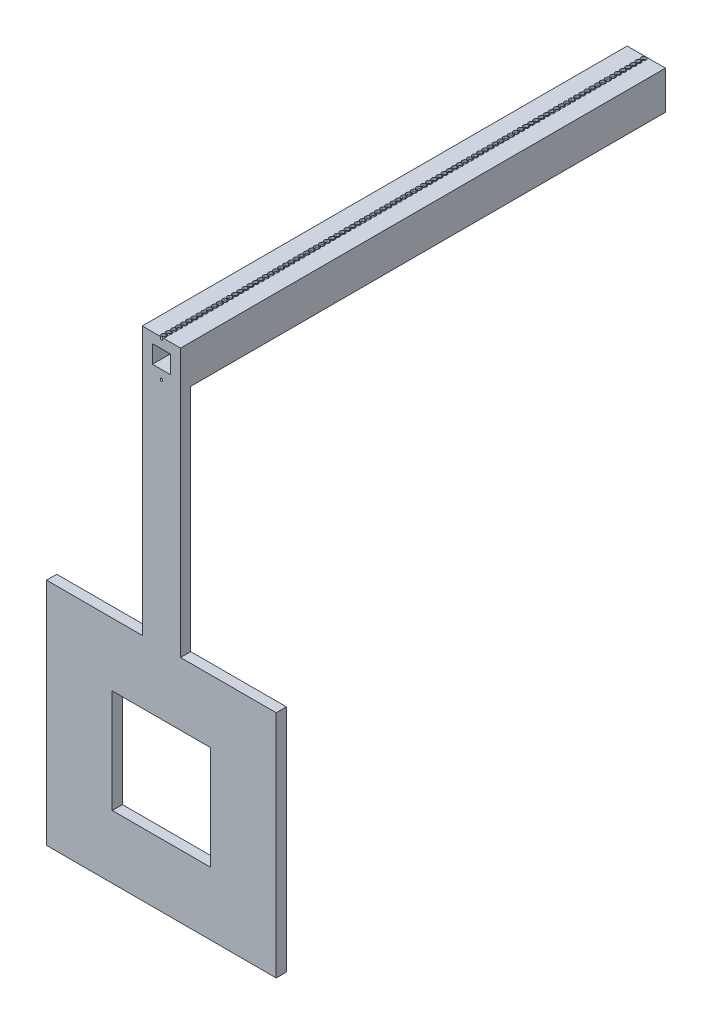
from build123d import *

# Parameters (mm, degrees)
SKETCH1_W                = 7.5
SKETCH1_H                = 7.5
SKETCH1_W_2              = 3.5
SKETCH1_H_2              = 3.5
BOSS_EXTRUDE1_DEPTH      = 95
SKETCH2_W                = 19.264715996
SKETCH2_H                = 20.292256916
BOSS_EXTRUDE2_DEPTH      = 2
SKETCH5_R                = 0.505131084
CUT_EXTRUDE2_DEPTH       = 0.5
LPATTERN1_COUNT          = 100
LPATTERN1_PITCH          = 1
MIRROR1_COPY_1_SKETCH_R  = 0.505131084
MIRROR1_COPY_1_DEPTH     = 0.5
MIRROR1_COPY_2_SKETCH_R  = 0.505131084
MIRROR1_COPY_2_DEPTH     = 0.5
MIRROR1_COPY_3_SKETCH_R  = 0.505131084
MIRROR1_COPY_3_DEPTH     = 0.5
MIRROR1_COPY_4_SKETCH_R  = 0.505131084
MIRROR1_COPY_4_DEPTH     = 0.5
MIRROR1_COPY_5_SKETCH_R  = 0.505131084
MIRROR1_COPY_5_DEPTH     = 0.5
MIRROR1_COPY_6_SKETCH_R  = 0.505131084
MIRROR1_COPY_6_DEPTH     = 0.5
MIRROR1_COPY_7_SKETCH_R  = 0.505131084
MIRROR1_COPY_7_DEPTH     = 0.5
MIRROR1_COPY_8_SKETCH_R  = 0.505131084
MIRROR1_COPY_8_DEPTH     = 0.5
MIRROR1_COPY_9_SKETCH_R  = 0.505131084
MIRROR1_COPY_9_DEPTH     = 0.5
MIRROR1_COPY_10_SKETCH_R = 0.505131084
MIRROR1_COPY_10_DEPTH    = 0.5
MIRROR1_COPY_11_SKETCH_R = 0.505131084
MIRROR1_COPY_11_DEPTH    = 0.5
MIRROR1_COPY_12_SKETCH_R = 0.505131084
MIRROR1_COPY_12_DEPTH    = 0.5
MIRROR1_COPY_13_SKETCH_R = 0.505131084
MIRROR1_COPY_13_DEPTH    = 0.5
MIRROR1_COPY_14_SKETCH_R = 0.505131084
MIRROR1_COPY_14_DEPTH    = 0.5
MIRROR1_COPY_15_SKETCH_R = 0.505131084
MIRROR1_COPY_15_DEPTH    = 0.5
MIRROR1_COPY_16_SKETCH_R = 0.505131084
MIRROR1_COPY_16_DEPTH    = 0.5
MIRROR1_COPY_17_SKETCH_R = 0.505131084
MIRROR1_COPY_17_DEPTH    = 0.5
MIRROR1_COPY_18_SKETCH_R = 0.505131084
MIRROR1_COPY_18_DEPTH    = 0.5
MIRROR1_COPY_19_SKETCH_R = 0.505131084
MIRROR1_COPY_19_DEPTH    = 0.5
MIRROR1_COPY_20_SKETCH_R = 0.505131084
MIRROR1_COPY_20_DEPTH    = 0.5
MIRROR1_COPY_21_SKETCH_R = 0.505131084
MIRROR1_COPY_21_DEPTH    = 0.5
MIRROR1_COPY_22_SKETCH_R = 0.505131084
MIRROR1_COPY_22_DEPTH    = 0.5
MIRROR1_COPY_23_SKETCH_R = 0.505131084
MIRROR1_COPY_23_DEPTH    = 0.5
MIRROR1_COPY_24_SKETCH_R = 0.505131084
MIRROR1_COPY_24_DEPTH    = 0.5
MIRROR1_COPY_25_SKETCH_R = 0.505131084
MIRROR1_COPY_25_DEPTH    = 0.5
MIRROR1_COPY_26_SKETCH_R = 0.505131084
MIRROR1_COPY_26_DEPTH    = 0.5
MIRROR1_COPY_27_SKETCH_R = 0.505131084
MIRROR1_COPY_27_DEPTH    = 0.5
MIRROR1_COPY_28_SKETCH_R = 0.505131084
MIRROR1_COPY_28_DEPTH    = 0.5
MIRROR1_COPY_29_SKETCH_R = 0.505131084
MIRROR1_COPY_29_DEPTH    = 0.5
MIRROR1_COPY_30_SKETCH_R = 0.505131084
MIRROR1_COPY_30_DEPTH    = 0.5
MIRROR1_COPY_31_SKETCH_R = 0.505131084
MIRROR1_COPY_31_DEPTH    = 0.5
MIRROR1_COPY_32_SKETCH_R = 0.505131084
MIRROR1_COPY_32_DEPTH    = 0.5
MIRROR1_COPY_33_SKETCH_R = 0.505131084
MIRROR1_COPY_33_DEPTH    = 0.5
MIRROR1_COPY_34_SKETCH_R = 0.505131084
MIRROR1_COPY_34_DEPTH    = 0.5
MIRROR1_COPY_35_SKETCH_R = 0.505131084
MIRROR1_COPY_35_DEPTH    = 0.5
MIRROR1_COPY_36_SKETCH_R = 0.505131084
MIRROR1_COPY_36_DEPTH    = 0.5
MIRROR1_COPY_37_SKETCH_R = 0.505131084
MIRROR1_COPY_37_DEPTH    = 0.5
MIRROR1_COPY_38_SKETCH_R = 0.505131084
MIRROR1_COPY_38_DEPTH    = 0.5
MIRROR1_COPY_39_SKETCH_R = 0.505131084
MIRROR1_COPY_39_DEPTH    = 0.5
MIRROR1_COPY_40_SKETCH_R = 0.505131084
MIRROR1_COPY_40_DEPTH    = 0.5
MIRROR1_COPY_41_SKETCH_R = 0.505131084
MIRROR1_COPY_41_DEPTH    = 0.5
MIRROR1_COPY_42_SKETCH_R = 0.505131084
MIRROR1_COPY_42_DEPTH    = 0.5
MIRROR1_COPY_43_SKETCH_R = 0.505131084
MIRROR1_COPY_43_DEPTH    = 0.5
MIRROR1_COPY_44_SKETCH_R = 0.505131084
MIRROR1_COPY_44_DEPTH    = 0.5
MIRROR1_COPY_45_SKETCH_R = 0.505131084
MIRROR1_COPY_45_DEPTH    = 0.5
MIRROR1_COPY_46_SKETCH_R = 0.505131084
MIRROR1_COPY_46_DEPTH    = 0.5
MIRROR1_COPY_47_SKETCH_R = 0.505131084
MIRROR1_COPY_47_DEPTH    = 0.5
MIRROR1_COPY_48_SKETCH_R = 0.505131084
MIRROR1_COPY_48_DEPTH    = 0.5
MIRROR1_COPY_49_SKETCH_R = 0.505131084
MIRROR1_COPY_49_DEPTH    = 0.5
MIRROR1_COPY_50_SKETCH_R = 0.505131084
MIRROR1_COPY_50_DEPTH    = 0.5
MIRROR1_COPY_51_SKETCH_R = 0.505131084
MIRROR1_COPY_51_DEPTH    = 0.5
MIRROR1_COPY_52_SKETCH_R = 0.505131084
MIRROR1_COPY_52_DEPTH    = 0.5
MIRROR1_COPY_53_SKETCH_R = 0.505131084
MIRROR1_COPY_53_DEPTH    = 0.5
MIRROR1_COPY_54_SKETCH_R = 0.505131084
MIRROR1_COPY_54_DEPTH    = 0.5
MIRROR1_COPY_55_SKETCH_R = 0.505131084
MIRROR1_COPY_55_DEPTH    = 0.5
MIRROR1_COPY_56_SKETCH_R = 0.505131084
MIRROR1_COPY_56_DEPTH    = 0.5
MIRROR1_COPY_57_SKETCH_R = 0.505131084
MIRROR1_COPY_57_DEPTH    = 0.5
MIRROR1_COPY_58_SKETCH_R = 0.505131084
MIRROR1_COPY_58_DEPTH    = 0.5
MIRROR1_COPY_59_SKETCH_R = 0.505131084
MIRROR1_COPY_59_DEPTH    = 0.5
MIRROR1_COPY_60_SKETCH_R = 0.505131084
MIRROR1_COPY_60_DEPTH    = 0.5
MIRROR1_COPY_61_SKETCH_R = 0.505131084
MIRROR1_COPY_61_DEPTH    = 0.5
MIRROR1_COPY_62_SKETCH_R = 0.505131084
MIRROR1_COPY_62_DEPTH    = 0.5
MIRROR1_COPY_63_SKETCH_R = 0.505131084
MIRROR1_COPY_63_DEPTH    = 0.5
MIRROR1_COPY_64_SKETCH_R = 0.505131084
MIRROR1_COPY_64_DEPTH    = 0.5
MIRROR1_COPY_65_SKETCH_R = 0.505131084
MIRROR1_COPY_65_DEPTH    = 0.5
MIRROR1_COPY_66_SKETCH_R = 0.505131084
MIRROR1_COPY_66_DEPTH    = 0.5
MIRROR1_COPY_67_SKETCH_R = 0.505131084
MIRROR1_COPY_67_DEPTH    = 0.5
MIRROR1_COPY_68_SKETCH_R = 0.505131084
MIRROR1_COPY_68_DEPTH    = 0.5
MIRROR1_COPY_69_SKETCH_R = 0.505131084
MIRROR1_COPY_69_DEPTH    = 0.5
MIRROR1_COPY_70_SKETCH_R = 0.505131084
MIRROR1_COPY_70_DEPTH    = 0.5
MIRROR1_COPY_71_SKETCH_R = 0.505131084
MIRROR1_COPY_71_DEPTH    = 0.5
MIRROR1_COPY_72_SKETCH_R = 0.505131084
MIRROR1_COPY_72_DEPTH    = 0.5
MIRROR1_COPY_73_SKETCH_R = 0.505131084
MIRROR1_COPY_73_DEPTH    = 0.5
MIRROR1_COPY_74_SKETCH_R = 0.505131084
MIRROR1_COPY_74_DEPTH    = 0.5
MIRROR1_COPY_75_SKETCH_R = 0.505131084
MIRROR1_COPY_75_DEPTH    = 0.5
MIRROR1_COPY_76_SKETCH_R = 0.505131084
MIRROR1_COPY_76_DEPTH    = 0.5
MIRROR1_COPY_77_SKETCH_R = 0.505131084
MIRROR1_COPY_77_DEPTH    = 0.5
MIRROR1_COPY_78_SKETCH_R = 0.505131084
MIRROR1_COPY_78_DEPTH    = 0.5
MIRROR1_COPY_79_SKETCH_R = 0.505131084
MIRROR1_COPY_79_DEPTH    = 0.5
MIRROR1_COPY_80_SKETCH_R = 0.505131084
MIRROR1_COPY_80_DEPTH    = 0.5
MIRROR1_COPY_81_SKETCH_R = 0.505131084
MIRROR1_COPY_81_DEPTH    = 0.5
MIRROR1_COPY_82_SKETCH_R = 0.505131084
MIRROR1_COPY_82_DEPTH    = 0.5
MIRROR1_COPY_83_SKETCH_R = 0.505131084
MIRROR1_COPY_83_DEPTH    = 0.5
MIRROR1_COPY_84_SKETCH_R = 0.505131084
MIRROR1_COPY_84_DEPTH    = 0.5
MIRROR1_COPY_85_SKETCH_R = 0.505131084
MIRROR1_COPY_85_DEPTH    = 0.5
MIRROR1_COPY_86_SKETCH_R = 0.505131084
MIRROR1_COPY_86_DEPTH    = 0.5
MIRROR1_COPY_87_SKETCH_R = 0.505131084
MIRROR1_COPY_87_DEPTH    = 0.5
MIRROR1_COPY_88_SKETCH_R = 0.505131084
MIRROR1_COPY_88_DEPTH    = 0.5
MIRROR1_COPY_89_SKETCH_R = 0.505131084
MIRROR1_COPY_89_DEPTH    = 0.5
MIRROR1_COPY_90_SKETCH_R = 0.505131084
MIRROR1_COPY_90_DEPTH    = 0.5
MIRROR1_COPY_91_SKETCH_R = 0.505131084
MIRROR1_COPY_91_DEPTH    = 0.5
MIRROR1_COPY_92_SKETCH_R = 0.505131084
MIRROR1_COPY_92_DEPTH    = 0.5
MIRROR1_COPY_93_SKETCH_R = 0.505131084
MIRROR1_COPY_93_DEPTH    = 0.5
MIRROR1_COPY_94_SKETCH_R = 0.505131084
MIRROR1_COPY_94_DEPTH    = 0.5
MIRROR1_COPY_95_SKETCH_R = 0.505131084
MIRROR1_COPY_95_DEPTH    = 0.5
MIRROR1_COPY_96_SKETCH_R = 0.505131084
MIRROR1_COPY_96_DEPTH    = 0.5
MIRROR1_COPY_97_SKETCH_R = 0.505131084
MIRROR1_COPY_97_DEPTH    = 0.5
MIRROR1_COPY_98_SKETCH_R = 0.505131084
MIRROR1_COPY_98_DEPTH    = 0.5
MIRROR1_COPY_99_SKETCH_R = 0.505131084
MIRROR1_COPY_99_DEPTH    = 0.5


with BuildPart() as part:
    # Sketch1 → Boss-Extrude1 (new body)
    with BuildSketch(Plane.XY):
        Rectangle(SKETCH1_W, SKETCH1_H)
        Rectangle(SKETCH1_W_2, SKETCH1_H_2, mode=Mode.SUBTRACT)
    extrude(amount=BOSS_EXTRUDE1_DEPTH)

    # Sketch2 → Boss-Extrude2 (add)
    with BuildSketch(Plane.XY.offset(95)):
        Polygon((3.75, -3.75), (-3.75, -3.75), (-3.75, -48.75), (-22.5, -48.75), (-22.5, -93.75), (22.5, -93.75), (22.5, -48.75), (3.75, -48.75), align=None)
        with Locations((0, -71.25)):
            Rectangle(SKETCH2_W, SKETCH2_H, mode=Mode.SUBTRACT)
    extrude(amount=-BOSS_EXTRUDE2_DEPTH)

    # Sketch5 → Cut-Extrude2 (cut)
    with BuildSketch(Plane(origin=(0, 3.75, 0), x_dir=(1, 0, 0), z_dir=(0, 1, 0))):
        with Locations(Location((0, -0.542844407, 0), (0, 0, 270))):
            Circle(SKETCH5_R)
    cut_extrude2 = extrude(amount=-CUT_EXTRUDE2_DEPTH, mode=Mode.SUBTRACT)

    # LPattern1: Cut-Extrude2 ×100
    with Locations(*[(0, 0, i * LPATTERN1_PITCH) for i in range(1, LPATTERN1_COUNT)]):
        add(cut_extrude2, mode=Mode.SUBTRACT)

    # Mirror1: Cut-Extrude2 across plane
    add(cut_extrude2.mirror(Plane.ZX), mode=Mode.SUBTRACT)

    # Mirror1 copy 1 sketch → Mirror1 copy 1 (cut)
    with BuildSketch(Plane(origin=(0, -3.75, 1), x_dir=(1, 0, 0), z_dir=(0, -1, 0))):
        with Locations((0, 0.542844407)):
            Circle(MIRROR1_COPY_1_SKETCH_R)
    extrude(amount=-MIRROR1_COPY_1_DEPTH, mode=Mode.SUBTRACT)

    # Mirror1 copy 2 sketch → Mirror1 copy 2 (cut)
    with BuildSketch(Plane(origin=(0, -3.75, 2), x_dir=(1, 0, 0), z_dir=(0, -1, 0))):
        with Locations((0, 0.542844407)):
            Circle(MIRROR1_COPY_2_SKETCH_R)
    extrude(amount=-MIRROR1_COPY_2_DEPTH, mode=Mode.SUBTRACT)

    # Mirror1 copy 3 sketch → Mirror1 copy 3 (cut)
    with BuildSketch(Plane(origin=(0, -3.75, 3), x_dir=(1, 0, 0), z_dir=(0, -1, 0))):
        with Locations((0, 0.542844407)):
            Circle(MIRROR1_COPY_3_SKETCH_R)
    extrude(amount=-MIRROR1_COPY_3_DEPTH, mode=Mode.SUBTRACT)

    # Mirror1 copy 4 sketch → Mirror1 copy 4 (cut)
    with BuildSketch(Plane(origin=(0, -3.75, 4), x_dir=(1, 0, 0), z_dir=(0, -1, 0))):
        with Locations((0, 0.542844407)):
            Circle(MIRROR1_COPY_4_SKETCH_R)
    extrude(amount=-MIRROR1_COPY_4_DEPTH, mode=Mode.SUBTRACT)

    # Mirror1 copy 5 sketch → Mirror1 copy 5 (cut)
    with BuildSketch(Plane(origin=(0, -3.75, 5), x_dir=(1, 0, 0), z_dir=(0, -1, 0))):
        with Locations((0, 0.542844407)):
            Circle(MIRROR1_COPY_5_SKETCH_R)
    extrude(amount=-MIRROR1_COPY_5_DEPTH, mode=Mode.SUBTRACT)

    # Mirror1 copy 6 sketch → Mirror1 copy 6 (cut)
    with BuildSketch(Plane(origin=(0, -3.75, 6), x_dir=(1, 0, 0), z_dir=(0, -1, 0))):
        with Locations((0, 0.542844407)):
            Circle(MIRROR1_COPY_6_SKETCH_R)
    extrude(amount=-MIRROR1_COPY_6_DEPTH, mode=Mode.SUBTRACT)

    # Mirror1 copy 7 sketch → Mirror1 copy 7 (cut)
    with BuildSketch(Plane(origin=(0, -3.75, 7), x_dir=(1, 0, 0), z_dir=(0, -1, 0))):
        with Locations((0, 0.542844407)):
            Circle(MIRROR1_COPY_7_SKETCH_R)
    extrude(amount=-MIRROR1_COPY_7_DEPTH, mode=Mode.SUBTRACT)

    # Mirror1 copy 8 sketch → Mirror1 copy 8 (cut)
    with BuildSketch(Plane(origin=(0, -3.75, 8), x_dir=(1, 0, 0), z_dir=(0, -1, 0))):
        with Locations((0, 0.542844407)):
            Circle(MIRROR1_COPY_8_SKETCH_R)
    extrude(amount=-MIRROR1_COPY_8_DEPTH, mode=Mode.SUBTRACT)

    # Mirror1 copy 9 sketch → Mirror1 copy 9 (cut)
    with BuildSketch(Plane(origin=(0, -3.75, 9), x_dir=(1, 0, 0), z_dir=(0, -1, 0))):
        with Locations((0, 0.542844407)):
            Circle(MIRROR1_COPY_9_SKETCH_R)
    extrude(amount=-MIRROR1_COPY_9_DEPTH, mode=Mode.SUBTRACT)

    # Mirror1 copy 10 sketch → Mirror1 copy 10 (cut)
    with BuildSketch(Plane(origin=(0, -3.75, 10), x_dir=(1, 0, 0), z_dir=(0, -1, 0))):
        with Locations((0, 0.542844407)):
            Circle(MIRROR1_COPY_10_SKETCH_R)
    extrude(amount=-MIRROR1_COPY_10_DEPTH, mode=Mode.SUBTRACT)

    # Mirror1 copy 11 sketch → Mirror1 copy 11 (cut)
    with BuildSketch(Plane(origin=(0, -3.75, 11), x_dir=(1, 0, 0), z_dir=(0, -1, 0))):
        with Locations((0, 0.542844407)):
            Circle(MIRROR1_COPY_11_SKETCH_R)
    extrude(amount=-MIRROR1_COPY_11_DEPTH, mode=Mode.SUBTRACT)

    # Mirror1 copy 12 sketch → Mirror1 copy 12 (cut)
    with BuildSketch(Plane(origin=(0, -3.75, 12), x_dir=(1, 0, 0), z_dir=(0, -1, 0))):
        with Locations((0, 0.542844407)):
            Circle(MIRROR1_COPY_12_SKETCH_R)
    extrude(amount=-MIRROR1_COPY_12_DEPTH, mode=Mode.SUBTRACT)

    # Mirror1 copy 13 sketch → Mirror1 copy 13 (cut)
    with BuildSketch(Plane(origin=(0, -3.75, 13), x_dir=(1, 0, 0), z_dir=(0, -1, 0))):
        with Locations((0, 0.542844407)):
            Circle(MIRROR1_COPY_13_SKETCH_R)
    extrude(amount=-MIRROR1_COPY_13_DEPTH, mode=Mode.SUBTRACT)

    # Mirror1 copy 14 sketch → Mirror1 copy 14 (cut)
    with BuildSketch(Plane(origin=(0, -3.75, 14), x_dir=(1, 0, 0), z_dir=(0, -1, 0))):
        with Locations((0, 0.542844407)):
            Circle(MIRROR1_COPY_14_SKETCH_R)
    extrude(amount=-MIRROR1_COPY_14_DEPTH, mode=Mode.SUBTRACT)

    # Mirror1 copy 15 sketch → Mirror1 copy 15 (cut)
    with BuildSketch(Plane(origin=(0, -3.75, 15), x_dir=(1, 0, 0), z_dir=(0, -1, 0))):
        with Locations((0, 0.542844407)):
            Circle(MIRROR1_COPY_15_SKETCH_R)
    extrude(amount=-MIRROR1_COPY_15_DEPTH, mode=Mode.SUBTRACT)

    # Mirror1 copy 16 sketch → Mirror1 copy 16 (cut)
    with BuildSketch(Plane(origin=(0, -3.75, 16), x_dir=(1, 0, 0), z_dir=(0, -1, 0))):
        with Locations((0, 0.542844407)):
            Circle(MIRROR1_COPY_16_SKETCH_R)
    extrude(amount=-MIRROR1_COPY_16_DEPTH, mode=Mode.SUBTRACT)

    # Mirror1 copy 17 sketch → Mirror1 copy 17 (cut)
    with BuildSketch(Plane(origin=(0, -3.75, 17), x_dir=(1, 0, 0), z_dir=(0, -1, 0))):
        with Locations((0, 0.542844407)):
            Circle(MIRROR1_COPY_17_SKETCH_R)
    extrude(amount=-MIRROR1_COPY_17_DEPTH, mode=Mode.SUBTRACT)

    # Mirror1 copy 18 sketch → Mirror1 copy 18 (cut)
    with BuildSketch(Plane(origin=(0, -3.75, 18), x_dir=(1, 0, 0), z_dir=(0, -1, 0))):
        with Locations((0, 0.542844407)):
            Circle(MIRROR1_COPY_18_SKETCH_R)
    extrude(amount=-MIRROR1_COPY_18_DEPTH, mode=Mode.SUBTRACT)

    # Mirror1 copy 19 sketch → Mirror1 copy 19 (cut)
    with BuildSketch(Plane(origin=(0, -3.75, 19), x_dir=(1, 0, 0), z_dir=(0, -1, 0))):
        with Locations((0, 0.542844407)):
            Circle(MIRROR1_COPY_19_SKETCH_R)
    extrude(amount=-MIRROR1_COPY_19_DEPTH, mode=Mode.SUBTRACT)

    # Mirror1 copy 20 sketch → Mirror1 copy 20 (cut)
    with BuildSketch(Plane(origin=(0, -3.75, 20), x_dir=(1, 0, 0), z_dir=(0, -1, 0))):
        with Locations((0, 0.542844407)):
            Circle(MIRROR1_COPY_20_SKETCH_R)
    extrude(amount=-MIRROR1_COPY_20_DEPTH, mode=Mode.SUBTRACT)

    # Mirror1 copy 21 sketch → Mirror1 copy 21 (cut)
    with BuildSketch(Plane(origin=(0, -3.75, 21), x_dir=(1, 0, 0), z_dir=(0, -1, 0))):
        with Locations((0, 0.542844407)):
            Circle(MIRROR1_COPY_21_SKETCH_R)
    extrude(amount=-MIRROR1_COPY_21_DEPTH, mode=Mode.SUBTRACT)

    # Mirror1 copy 22 sketch → Mirror1 copy 22 (cut)
    with BuildSketch(Plane(origin=(0, -3.75, 22), x_dir=(1, 0, 0), z_dir=(0, -1, 0))):
        with Locations((0, 0.542844407)):
            Circle(MIRROR1_COPY_22_SKETCH_R)
    extrude(amount=-MIRROR1_COPY_22_DEPTH, mode=Mode.SUBTRACT)

    # Mirror1 copy 23 sketch → Mirror1 copy 23 (cut)
    with BuildSketch(Plane(origin=(0, -3.75, 23), x_dir=(1, 0, 0), z_dir=(0, -1, 0))):
        with Locations((0, 0.542844407)):
            Circle(MIRROR1_COPY_23_SKETCH_R)
    extrude(amount=-MIRROR1_COPY_23_DEPTH, mode=Mode.SUBTRACT)

    # Mirror1 copy 24 sketch → Mirror1 copy 24 (cut)
    with BuildSketch(Plane(origin=(0, -3.75, 24), x_dir=(1, 0, 0), z_dir=(0, -1, 0))):
        with Locations((0, 0.542844407)):
            Circle(MIRROR1_COPY_24_SKETCH_R)
    extrude(amount=-MIRROR1_COPY_24_DEPTH, mode=Mode.SUBTRACT)

    # Mirror1 copy 25 sketch → Mirror1 copy 25 (cut)
    with BuildSketch(Plane(origin=(0, -3.75, 25), x_dir=(1, 0, 0), z_dir=(0, -1, 0))):
        with Locations((0, 0.542844407)):
            Circle(MIRROR1_COPY_25_SKETCH_R)
    extrude(amount=-MIRROR1_COPY_25_DEPTH, mode=Mode.SUBTRACT)

    # Mirror1 copy 26 sketch → Mirror1 copy 26 (cut)
    with BuildSketch(Plane(origin=(0, -3.75, 26), x_dir=(1, 0, 0), z_dir=(0, -1, 0))):
        with Locations((0, 0.542844407)):
            Circle(MIRROR1_COPY_26_SKETCH_R)
    extrude(amount=-MIRROR1_COPY_26_DEPTH, mode=Mode.SUBTRACT)

    # Mirror1 copy 27 sketch → Mirror1 copy 27 (cut)
    with BuildSketch(Plane(origin=(0, -3.75, 27), x_dir=(1, 0, 0), z_dir=(0, -1, 0))):
        with Locations((0, 0.542844407)):
            Circle(MIRROR1_COPY_27_SKETCH_R)
    extrude(amount=-MIRROR1_COPY_27_DEPTH, mode=Mode.SUBTRACT)

    # Mirror1 copy 28 sketch → Mirror1 copy 28 (cut)
    with BuildSketch(Plane(origin=(0, -3.75, 28), x_dir=(1, 0, 0), z_dir=(0, -1, 0))):
        with Locations((0, 0.542844407)):
            Circle(MIRROR1_COPY_28_SKETCH_R)
    extrude(amount=-MIRROR1_COPY_28_DEPTH, mode=Mode.SUBTRACT)

    # Mirror1 copy 29 sketch → Mirror1 copy 29 (cut)
    with BuildSketch(Plane(origin=(0, -3.75, 29), x_dir=(1, 0, 0), z_dir=(0, -1, 0))):
        with Locations((0, 0.542844407)):
            Circle(MIRROR1_COPY_29_SKETCH_R)
    extrude(amount=-MIRROR1_COPY_29_DEPTH, mode=Mode.SUBTRACT)

    # Mirror1 copy 30 sketch → Mirror1 copy 30 (cut)
    with BuildSketch(Plane(origin=(0, -3.75, 30), x_dir=(1, 0, 0), z_dir=(0, -1, 0))):
        with Locations((0, 0.542844407)):
            Circle(MIRROR1_COPY_30_SKETCH_R)
    extrude(amount=-MIRROR1_COPY_30_DEPTH, mode=Mode.SUBTRACT)

    # Mirror1 copy 31 sketch → Mirror1 copy 31 (cut)
    with BuildSketch(Plane(origin=(0, -3.75, 31), x_dir=(1, 0, 0), z_dir=(0, -1, 0))):
        with Locations((0, 0.542844407)):
            Circle(MIRROR1_COPY_31_SKETCH_R)
    extrude(amount=-MIRROR1_COPY_31_DEPTH, mode=Mode.SUBTRACT)

    # Mirror1 copy 32 sketch → Mirror1 copy 32 (cut)
    with BuildSketch(Plane(origin=(0, -3.75, 32), x_dir=(1, 0, 0), z_dir=(0, -1, 0))):
        with Locations((0, 0.542844407)):
            Circle(MIRROR1_COPY_32_SKETCH_R)
    extrude(amount=-MIRROR1_COPY_32_DEPTH, mode=Mode.SUBTRACT)

    # Mirror1 copy 33 sketch → Mirror1 copy 33 (cut)
    with BuildSketch(Plane(origin=(0, -3.75, 33), x_dir=(1, 0, 0), z_dir=(0, -1, 0))):
        with Locations((0, 0.542844407)):
            Circle(MIRROR1_COPY_33_SKETCH_R)
    extrude(amount=-MIRROR1_COPY_33_DEPTH, mode=Mode.SUBTRACT)

    # Mirror1 copy 34 sketch → Mirror1 copy 34 (cut)
    with BuildSketch(Plane(origin=(0, -3.75, 34), x_dir=(1, 0, 0), z_dir=(0, -1, 0))):
        with Locations((0, 0.542844407)):
            Circle(MIRROR1_COPY_34_SKETCH_R)
    extrude(amount=-MIRROR1_COPY_34_DEPTH, mode=Mode.SUBTRACT)

    # Mirror1 copy 35 sketch → Mirror1 copy 35 (cut)
    with BuildSketch(Plane(origin=(0, -3.75, 35), x_dir=(1, 0, 0), z_dir=(0, -1, 0))):
        with Locations((0, 0.542844407)):
            Circle(MIRROR1_COPY_35_SKETCH_R)
    extrude(amount=-MIRROR1_COPY_35_DEPTH, mode=Mode.SUBTRACT)

    # Mirror1 copy 36 sketch → Mirror1 copy 36 (cut)
    with BuildSketch(Plane(origin=(0, -3.75, 36), x_dir=(1, 0, 0), z_dir=(0, -1, 0))):
        with Locations((0, 0.542844407)):
            Circle(MIRROR1_COPY_36_SKETCH_R)
    extrude(amount=-MIRROR1_COPY_36_DEPTH, mode=Mode.SUBTRACT)

    # Mirror1 copy 37 sketch → Mirror1 copy 37 (cut)
    with BuildSketch(Plane(origin=(0, -3.75, 37), x_dir=(1, 0, 0), z_dir=(0, -1, 0))):
        with Locations((0, 0.542844407)):
            Circle(MIRROR1_COPY_37_SKETCH_R)
    extrude(amount=-MIRROR1_COPY_37_DEPTH, mode=Mode.SUBTRACT)

    # Mirror1 copy 38 sketch → Mirror1 copy 38 (cut)
    with BuildSketch(Plane(origin=(0, -3.75, 38), x_dir=(1, 0, 0), z_dir=(0, -1, 0))):
        with Locations((0, 0.542844407)):
            Circle(MIRROR1_COPY_38_SKETCH_R)
    extrude(amount=-MIRROR1_COPY_38_DEPTH, mode=Mode.SUBTRACT)

    # Mirror1 copy 39 sketch → Mirror1 copy 39 (cut)
    with BuildSketch(Plane(origin=(0, -3.75, 39), x_dir=(1, 0, 0), z_dir=(0, -1, 0))):
        with Locations((0, 0.542844407)):
            Circle(MIRROR1_COPY_39_SKETCH_R)
    extrude(amount=-MIRROR1_COPY_39_DEPTH, mode=Mode.SUBTRACT)

    # Mirror1 copy 40 sketch → Mirror1 copy 40 (cut)
    with BuildSketch(Plane(origin=(0, -3.75, 40), x_dir=(1, 0, 0), z_dir=(0, -1, 0))):
        with Locations((0, 0.542844407)):
            Circle(MIRROR1_COPY_40_SKETCH_R)
    extrude(amount=-MIRROR1_COPY_40_DEPTH, mode=Mode.SUBTRACT)

    # Mirror1 copy 41 sketch → Mirror1 copy 41 (cut)
    with BuildSketch(Plane(origin=(0, -3.75, 41), x_dir=(1, 0, 0), z_dir=(0, -1, 0))):
        with Locations((0, 0.542844407)):
            Circle(MIRROR1_COPY_41_SKETCH_R)
    extrude(amount=-MIRROR1_COPY_41_DEPTH, mode=Mode.SUBTRACT)

    # Mirror1 copy 42 sketch → Mirror1 copy 42 (cut)
    with BuildSketch(Plane(origin=(0, -3.75, 42), x_dir=(1, 0, 0), z_dir=(0, -1, 0))):
        with Locations((0, 0.542844407)):
            Circle(MIRROR1_COPY_42_SKETCH_R)
    extrude(amount=-MIRROR1_COPY_42_DEPTH, mode=Mode.SUBTRACT)

    # Mirror1 copy 43 sketch → Mirror1 copy 43 (cut)
    with BuildSketch(Plane(origin=(0, -3.75, 43), x_dir=(1, 0, 0), z_dir=(0, -1, 0))):
        with Locations((0, 0.542844407)):
            Circle(MIRROR1_COPY_43_SKETCH_R)
    extrude(amount=-MIRROR1_COPY_43_DEPTH, mode=Mode.SUBTRACT)

    # Mirror1 copy 44 sketch → Mirror1 copy 44 (cut)
    with BuildSketch(Plane(origin=(0, -3.75, 44), x_dir=(1, 0, 0), z_dir=(0, -1, 0))):
        with Locations((0, 0.542844407)):
            Circle(MIRROR1_COPY_44_SKETCH_R)
    extrude(amount=-MIRROR1_COPY_44_DEPTH, mode=Mode.SUBTRACT)

    # Mirror1 copy 45 sketch → Mirror1 copy 45 (cut)
    with BuildSketch(Plane(origin=(0, -3.75, 45), x_dir=(1, 0, 0), z_dir=(0, -1, 0))):
        with Locations((0, 0.542844407)):
            Circle(MIRROR1_COPY_45_SKETCH_R)
    extrude(amount=-MIRROR1_COPY_45_DEPTH, mode=Mode.SUBTRACT)

    # Mirror1 copy 46 sketch → Mirror1 copy 46 (cut)
    with BuildSketch(Plane(origin=(0, -3.75, 46), x_dir=(1, 0, 0), z_dir=(0, -1, 0))):
        with Locations((0, 0.542844407)):
            Circle(MIRROR1_COPY_46_SKETCH_R)
    extrude(amount=-MIRROR1_COPY_46_DEPTH, mode=Mode.SUBTRACT)

    # Mirror1 copy 47 sketch → Mirror1 copy 47 (cut)
    with BuildSketch(Plane(origin=(0, -3.75, 47), x_dir=(1, 0, 0), z_dir=(0, -1, 0))):
        with Locations((0, 0.542844407)):
            Circle(MIRROR1_COPY_47_SKETCH_R)
    extrude(amount=-MIRROR1_COPY_47_DEPTH, mode=Mode.SUBTRACT)

    # Mirror1 copy 48 sketch → Mirror1 copy 48 (cut)
    with BuildSketch(Plane(origin=(0, -3.75, 48), x_dir=(1, 0, 0), z_dir=(0, -1, 0))):
        with Locations((0, 0.542844407)):
            Circle(MIRROR1_COPY_48_SKETCH_R)
    extrude(amount=-MIRROR1_COPY_48_DEPTH, mode=Mode.SUBTRACT)

    # Mirror1 copy 49 sketch → Mirror1 copy 49 (cut)
    with BuildSketch(Plane(origin=(0, -3.75, 49), x_dir=(1, 0, 0), z_dir=(0, -1, 0))):
        with Locations((0, 0.542844407)):
            Circle(MIRROR1_COPY_49_SKETCH_R)
    extrude(amount=-MIRROR1_COPY_49_DEPTH, mode=Mode.SUBTRACT)

    # Mirror1 copy 50 sketch → Mirror1 copy 50 (cut)
    with BuildSketch(Plane(origin=(0, -3.75, 50), x_dir=(1, 0, 0), z_dir=(0, -1, 0))):
        with Locations((0, 0.542844407)):
            Circle(MIRROR1_COPY_50_SKETCH_R)
    extrude(amount=-MIRROR1_COPY_50_DEPTH, mode=Mode.SUBTRACT)

    # Mirror1 copy 51 sketch → Mirror1 copy 51 (cut)
    with BuildSketch(Plane(origin=(0, -3.75, 51), x_dir=(1, 0, 0), z_dir=(0, -1, 0))):
        with Locations((0, 0.542844407)):
            Circle(MIRROR1_COPY_51_SKETCH_R)
    extrude(amount=-MIRROR1_COPY_51_DEPTH, mode=Mode.SUBTRACT)

    # Mirror1 copy 52 sketch → Mirror1 copy 52 (cut)
    with BuildSketch(Plane(origin=(0, -3.75, 52), x_dir=(1, 0, 0), z_dir=(0, -1, 0))):
        with Locations((0, 0.542844407)):
            Circle(MIRROR1_COPY_52_SKETCH_R)
    extrude(amount=-MIRROR1_COPY_52_DEPTH, mode=Mode.SUBTRACT)

    # Mirror1 copy 53 sketch → Mirror1 copy 53 (cut)
    with BuildSketch(Plane(origin=(0, -3.75, 53), x_dir=(1, 0, 0), z_dir=(0, -1, 0))):
        with Locations((0, 0.542844407)):
            Circle(MIRROR1_COPY_53_SKETCH_R)
    extrude(amount=-MIRROR1_COPY_53_DEPTH, mode=Mode.SUBTRACT)

    # Mirror1 copy 54 sketch → Mirror1 copy 54 (cut)
    with BuildSketch(Plane(origin=(0, -3.75, 54), x_dir=(1, 0, 0), z_dir=(0, -1, 0))):
        with Locations((0, 0.542844407)):
            Circle(MIRROR1_COPY_54_SKETCH_R)
    extrude(amount=-MIRROR1_COPY_54_DEPTH, mode=Mode.SUBTRACT)

    # Mirror1 copy 55 sketch → Mirror1 copy 55 (cut)
    with BuildSketch(Plane(origin=(0, -3.75, 55), x_dir=(1, 0, 0), z_dir=(0, -1, 0))):
        with Locations((0, 0.542844407)):
            Circle(MIRROR1_COPY_55_SKETCH_R)
    extrude(amount=-MIRROR1_COPY_55_DEPTH, mode=Mode.SUBTRACT)

    # Mirror1 copy 56 sketch → Mirror1 copy 56 (cut)
    with BuildSketch(Plane(origin=(0, -3.75, 56), x_dir=(1, 0, 0), z_dir=(0, -1, 0))):
        with Locations((0, 0.542844407)):
            Circle(MIRROR1_COPY_56_SKETCH_R)
    extrude(amount=-MIRROR1_COPY_56_DEPTH, mode=Mode.SUBTRACT)

    # Mirror1 copy 57 sketch → Mirror1 copy 57 (cut)
    with BuildSketch(Plane(origin=(0, -3.75, 57), x_dir=(1, 0, 0), z_dir=(0, -1, 0))):
        with Locations((0, 0.542844407)):
            Circle(MIRROR1_COPY_57_SKETCH_R)
    extrude(amount=-MIRROR1_COPY_57_DEPTH, mode=Mode.SUBTRACT)

    # Mirror1 copy 58 sketch → Mirror1 copy 58 (cut)
    with BuildSketch(Plane(origin=(0, -3.75, 58), x_dir=(1, 0, 0), z_dir=(0, -1, 0))):
        with Locations((0, 0.542844407)):
            Circle(MIRROR1_COPY_58_SKETCH_R)
    extrude(amount=-MIRROR1_COPY_58_DEPTH, mode=Mode.SUBTRACT)

    # Mirror1 copy 59 sketch → Mirror1 copy 59 (cut)
    with BuildSketch(Plane(origin=(0, -3.75, 59), x_dir=(1, 0, 0), z_dir=(0, -1, 0))):
        with Locations((0, 0.542844407)):
            Circle(MIRROR1_COPY_59_SKETCH_R)
    extrude(amount=-MIRROR1_COPY_59_DEPTH, mode=Mode.SUBTRACT)

    # Mirror1 copy 60 sketch → Mirror1 copy 60 (cut)
    with BuildSketch(Plane(origin=(0, -3.75, 60), x_dir=(1, 0, 0), z_dir=(0, -1, 0))):
        with Locations((0, 0.542844407)):
            Circle(MIRROR1_COPY_60_SKETCH_R)
    extrude(amount=-MIRROR1_COPY_60_DEPTH, mode=Mode.SUBTRACT)

    # Mirror1 copy 61 sketch → Mirror1 copy 61 (cut)
    with BuildSketch(Plane(origin=(0, -3.75, 61), x_dir=(1, 0, 0), z_dir=(0, -1, 0))):
        with Locations((0, 0.542844407)):
            Circle(MIRROR1_COPY_61_SKETCH_R)
    extrude(amount=-MIRROR1_COPY_61_DEPTH, mode=Mode.SUBTRACT)

    # Mirror1 copy 62 sketch → Mirror1 copy 62 (cut)
    with BuildSketch(Plane(origin=(0, -3.75, 62), x_dir=(1, 0, 0), z_dir=(0, -1, 0))):
        with Locations((0, 0.542844407)):
            Circle(MIRROR1_COPY_62_SKETCH_R)
    extrude(amount=-MIRROR1_COPY_62_DEPTH, mode=Mode.SUBTRACT)

    # Mirror1 copy 63 sketch → Mirror1 copy 63 (cut)
    with BuildSketch(Plane(origin=(0, -3.75, 63), x_dir=(1, 0, 0), z_dir=(0, -1, 0))):
        with Locations((0, 0.542844407)):
            Circle(MIRROR1_COPY_63_SKETCH_R)
    extrude(amount=-MIRROR1_COPY_63_DEPTH, mode=Mode.SUBTRACT)

    # Mirror1 copy 64 sketch → Mirror1 copy 64 (cut)
    with BuildSketch(Plane(origin=(0, -3.75, 64), x_dir=(1, 0, 0), z_dir=(0, -1, 0))):
        with Locations((0, 0.542844407)):
            Circle(MIRROR1_COPY_64_SKETCH_R)
    extrude(amount=-MIRROR1_COPY_64_DEPTH, mode=Mode.SUBTRACT)

    # Mirror1 copy 65 sketch → Mirror1 copy 65 (cut)
    with BuildSketch(Plane(origin=(0, -3.75, 65), x_dir=(1, 0, 0), z_dir=(0, -1, 0))):
        with Locations((0, 0.542844407)):
            Circle(MIRROR1_COPY_65_SKETCH_R)
    extrude(amount=-MIRROR1_COPY_65_DEPTH, mode=Mode.SUBTRACT)

    # Mirror1 copy 66 sketch → Mirror1 copy 66 (cut)
    with BuildSketch(Plane(origin=(0, -3.75, 66), x_dir=(1, 0, 0), z_dir=(0, -1, 0))):
        with Locations((0, 0.542844407)):
            Circle(MIRROR1_COPY_66_SKETCH_R)
    extrude(amount=-MIRROR1_COPY_66_DEPTH, mode=Mode.SUBTRACT)

    # Mirror1 copy 67 sketch → Mirror1 copy 67 (cut)
    with BuildSketch(Plane(origin=(0, -3.75, 67), x_dir=(1, 0, 0), z_dir=(0, -1, 0))):
        with Locations((0, 0.542844407)):
            Circle(MIRROR1_COPY_67_SKETCH_R)
    extrude(amount=-MIRROR1_COPY_67_DEPTH, mode=Mode.SUBTRACT)

    # Mirror1 copy 68 sketch → Mirror1 copy 68 (cut)
    with BuildSketch(Plane(origin=(0, -3.75, 68), x_dir=(1, 0, 0), z_dir=(0, -1, 0))):
        with Locations((0, 0.542844407)):
            Circle(MIRROR1_COPY_68_SKETCH_R)
    extrude(amount=-MIRROR1_COPY_68_DEPTH, mode=Mode.SUBTRACT)

    # Mirror1 copy 69 sketch → Mirror1 copy 69 (cut)
    with BuildSketch(Plane(origin=(0, -3.75, 69), x_dir=(1, 0, 0), z_dir=(0, -1, 0))):
        with Locations((0, 0.542844407)):
            Circle(MIRROR1_COPY_69_SKETCH_R)
    extrude(amount=-MIRROR1_COPY_69_DEPTH, mode=Mode.SUBTRACT)

    # Mirror1 copy 70 sketch → Mirror1 copy 70 (cut)
    with BuildSketch(Plane(origin=(0, -3.75, 70), x_dir=(1, 0, 0), z_dir=(0, -1, 0))):
        with Locations((0, 0.542844407)):
            Circle(MIRROR1_COPY_70_SKETCH_R)
    extrude(amount=-MIRROR1_COPY_70_DEPTH, mode=Mode.SUBTRACT)

    # Mirror1 copy 71 sketch → Mirror1 copy 71 (cut)
    with BuildSketch(Plane(origin=(0, -3.75, 71), x_dir=(1, 0, 0), z_dir=(0, -1, 0))):
        with Locations((0, 0.542844407)):
            Circle(MIRROR1_COPY_71_SKETCH_R)
    extrude(amount=-MIRROR1_COPY_71_DEPTH, mode=Mode.SUBTRACT)

    # Mirror1 copy 72 sketch → Mirror1 copy 72 (cut)
    with BuildSketch(Plane(origin=(0, -3.75, 72), x_dir=(1, 0, 0), z_dir=(0, -1, 0))):
        with Locations((0, 0.542844407)):
            Circle(MIRROR1_COPY_72_SKETCH_R)
    extrude(amount=-MIRROR1_COPY_72_DEPTH, mode=Mode.SUBTRACT)

    # Mirror1 copy 73 sketch → Mirror1 copy 73 (cut)
    with BuildSketch(Plane(origin=(0, -3.75, 73), x_dir=(1, 0, 0), z_dir=(0, -1, 0))):
        with Locations((0, 0.542844407)):
            Circle(MIRROR1_COPY_73_SKETCH_R)
    extrude(amount=-MIRROR1_COPY_73_DEPTH, mode=Mode.SUBTRACT)

    # Mirror1 copy 74 sketch → Mirror1 copy 74 (cut)
    with BuildSketch(Plane(origin=(0, -3.75, 74), x_dir=(1, 0, 0), z_dir=(0, -1, 0))):
        with Locations((0, 0.542844407)):
            Circle(MIRROR1_COPY_74_SKETCH_R)
    extrude(amount=-MIRROR1_COPY_74_DEPTH, mode=Mode.SUBTRACT)

    # Mirror1 copy 75 sketch → Mirror1 copy 75 (cut)
    with BuildSketch(Plane(origin=(0, -3.75, 75), x_dir=(1, 0, 0), z_dir=(0, -1, 0))):
        with Locations((0, 0.542844407)):
            Circle(MIRROR1_COPY_75_SKETCH_R)
    extrude(amount=-MIRROR1_COPY_75_DEPTH, mode=Mode.SUBTRACT)

    # Mirror1 copy 76 sketch → Mirror1 copy 76 (cut)
    with BuildSketch(Plane(origin=(0, -3.75, 76), x_dir=(1, 0, 0), z_dir=(0, -1, 0))):
        with Locations((0, 0.542844407)):
            Circle(MIRROR1_COPY_76_SKETCH_R)
    extrude(amount=-MIRROR1_COPY_76_DEPTH, mode=Mode.SUBTRACT)

    # Mirror1 copy 77 sketch → Mirror1 copy 77 (cut)
    with BuildSketch(Plane(origin=(0, -3.75, 77), x_dir=(1, 0, 0), z_dir=(0, -1, 0))):
        with Locations((0, 0.542844407)):
            Circle(MIRROR1_COPY_77_SKETCH_R)
    extrude(amount=-MIRROR1_COPY_77_DEPTH, mode=Mode.SUBTRACT)

    # Mirror1 copy 78 sketch → Mirror1 copy 78 (cut)
    with BuildSketch(Plane(origin=(0, -3.75, 78), x_dir=(1, 0, 0), z_dir=(0, -1, 0))):
        with Locations((0, 0.542844407)):
            Circle(MIRROR1_COPY_78_SKETCH_R)
    extrude(amount=-MIRROR1_COPY_78_DEPTH, mode=Mode.SUBTRACT)

    # Mirror1 copy 79 sketch → Mirror1 copy 79 (cut)
    with BuildSketch(Plane(origin=(0, -3.75, 79), x_dir=(1, 0, 0), z_dir=(0, -1, 0))):
        with Locations((0, 0.542844407)):
            Circle(MIRROR1_COPY_79_SKETCH_R)
    extrude(amount=-MIRROR1_COPY_79_DEPTH, mode=Mode.SUBTRACT)

    # Mirror1 copy 80 sketch → Mirror1 copy 80 (cut)
    with BuildSketch(Plane(origin=(0, -3.75, 80), x_dir=(1, 0, 0), z_dir=(0, -1, 0))):
        with Locations((0, 0.542844407)):
            Circle(MIRROR1_COPY_80_SKETCH_R)
    extrude(amount=-MIRROR1_COPY_80_DEPTH, mode=Mode.SUBTRACT)

    # Mirror1 copy 81 sketch → Mirror1 copy 81 (cut)
    with BuildSketch(Plane(origin=(0, -3.75, 81), x_dir=(1, 0, 0), z_dir=(0, -1, 0))):
        with Locations((0, 0.542844407)):
            Circle(MIRROR1_COPY_81_SKETCH_R)
    extrude(amount=-MIRROR1_COPY_81_DEPTH, mode=Mode.SUBTRACT)

    # Mirror1 copy 82 sketch → Mirror1 copy 82 (cut)
    with BuildSketch(Plane(origin=(0, -3.75, 82), x_dir=(1, 0, 0), z_dir=(0, -1, 0))):
        with Locations((0, 0.542844407)):
            Circle(MIRROR1_COPY_82_SKETCH_R)
    extrude(amount=-MIRROR1_COPY_82_DEPTH, mode=Mode.SUBTRACT)

    # Mirror1 copy 83 sketch → Mirror1 copy 83 (cut)
    with BuildSketch(Plane(origin=(0, -3.75, 83), x_dir=(1, 0, 0), z_dir=(0, -1, 0))):
        with Locations((0, 0.542844407)):
            Circle(MIRROR1_COPY_83_SKETCH_R)
    extrude(amount=-MIRROR1_COPY_83_DEPTH, mode=Mode.SUBTRACT)

    # Mirror1 copy 84 sketch → Mirror1 copy 84 (cut)
    with BuildSketch(Plane(origin=(0, -3.75, 84), x_dir=(1, 0, 0), z_dir=(0, -1, 0))):
        with Locations((0, 0.542844407)):
            Circle(MIRROR1_COPY_84_SKETCH_R)
    extrude(amount=-MIRROR1_COPY_84_DEPTH, mode=Mode.SUBTRACT)

    # Mirror1 copy 85 sketch → Mirror1 copy 85 (cut)
    with BuildSketch(Plane(origin=(0, -3.75, 85), x_dir=(1, 0, 0), z_dir=(0, -1, 0))):
        with Locations((0, 0.542844407)):
            Circle(MIRROR1_COPY_85_SKETCH_R)
    extrude(amount=-MIRROR1_COPY_85_DEPTH, mode=Mode.SUBTRACT)

    # Mirror1 copy 86 sketch → Mirror1 copy 86 (cut)
    with BuildSketch(Plane(origin=(0, -3.75, 86), x_dir=(1, 0, 0), z_dir=(0, -1, 0))):
        with Locations((0, 0.542844407)):
            Circle(MIRROR1_COPY_86_SKETCH_R)
    extrude(amount=-MIRROR1_COPY_86_DEPTH, mode=Mode.SUBTRACT)

    # Mirror1 copy 87 sketch → Mirror1 copy 87 (cut)
    with BuildSketch(Plane(origin=(0, -3.75, 87), x_dir=(1, 0, 0), z_dir=(0, -1, 0))):
        with Locations((0, 0.542844407)):
            Circle(MIRROR1_COPY_87_SKETCH_R)
    extrude(amount=-MIRROR1_COPY_87_DEPTH, mode=Mode.SUBTRACT)

    # Mirror1 copy 88 sketch → Mirror1 copy 88 (cut)
    with BuildSketch(Plane(origin=(0, -3.75, 88), x_dir=(1, 0, 0), z_dir=(0, -1, 0))):
        with Locations((0, 0.542844407)):
            Circle(MIRROR1_COPY_88_SKETCH_R)
    extrude(amount=-MIRROR1_COPY_88_DEPTH, mode=Mode.SUBTRACT)

    # Mirror1 copy 89 sketch → Mirror1 copy 89 (cut)
    with BuildSketch(Plane(origin=(0, -3.75, 89), x_dir=(1, 0, 0), z_dir=(0, -1, 0))):
        with Locations((0, 0.542844407)):
            Circle(MIRROR1_COPY_89_SKETCH_R)
    extrude(amount=-MIRROR1_COPY_89_DEPTH, mode=Mode.SUBTRACT)

    # Mirror1 copy 90 sketch → Mirror1 copy 90 (cut)
    with BuildSketch(Plane(origin=(0, -3.75, 90), x_dir=(1, 0, 0), z_dir=(0, -1, 0))):
        with Locations((0, 0.542844407)):
            Circle(MIRROR1_COPY_90_SKETCH_R)
    extrude(amount=-MIRROR1_COPY_90_DEPTH, mode=Mode.SUBTRACT)

    # Mirror1 copy 91 sketch → Mirror1 copy 91 (cut)
    with BuildSketch(Plane(origin=(0, -3.75, 91), x_dir=(1, 0, 0), z_dir=(0, -1, 0))):
        with Locations((0, 0.542844407)):
            Circle(MIRROR1_COPY_91_SKETCH_R)
    extrude(amount=-MIRROR1_COPY_91_DEPTH, mode=Mode.SUBTRACT)

    # Mirror1 copy 92 sketch → Mirror1 copy 92 (cut)
    with BuildSketch(Plane(origin=(0, -3.75, 92), x_dir=(1, 0, 0), z_dir=(0, -1, 0))):
        with Locations((0, 0.542844407)):
            Circle(MIRROR1_COPY_92_SKETCH_R)
    extrude(amount=-MIRROR1_COPY_92_DEPTH, mode=Mode.SUBTRACT)

    # Mirror1 copy 93 sketch → Mirror1 copy 93 (cut)
    with BuildSketch(Plane(origin=(0, -3.75, 93), x_dir=(1, 0, 0), z_dir=(0, -1, 0))):
        with Locations((0, 0.542844407)):
            Circle(MIRROR1_COPY_93_SKETCH_R)
    extrude(amount=-MIRROR1_COPY_93_DEPTH, mode=Mode.SUBTRACT)

    # Mirror1 copy 94 sketch → Mirror1 copy 94 (cut)
    with BuildSketch(Plane(origin=(0, -3.75, 94), x_dir=(1, 0, 0), z_dir=(0, -1, 0))):
        with Locations((0, 0.542844407)):
            Circle(MIRROR1_COPY_94_SKETCH_R)
    extrude(amount=-MIRROR1_COPY_94_DEPTH, mode=Mode.SUBTRACT)

    # Mirror1 copy 95 sketch → Mirror1 copy 95 (cut)
    with BuildSketch(Plane(origin=(0, -3.75, 95), x_dir=(1, 0, 0), z_dir=(0, -1, 0))):
        with Locations((0, 0.542844407)):
            Circle(MIRROR1_COPY_95_SKETCH_R)
    extrude(amount=-MIRROR1_COPY_95_DEPTH, mode=Mode.SUBTRACT)

    # Mirror1 copy 96 sketch → Mirror1 copy 96 (cut)
    with BuildSketch(Plane(origin=(0, -3.75, 96), x_dir=(1, 0, 0), z_dir=(0, -1, 0))):
        with Locations((0, 0.542844407)):
            Circle(MIRROR1_COPY_96_SKETCH_R)
    extrude(amount=-MIRROR1_COPY_96_DEPTH, mode=Mode.SUBTRACT)

    # Mirror1 copy 97 sketch → Mirror1 copy 97 (cut)
    with BuildSketch(Plane(origin=(0, -3.75, 97), x_dir=(1, 0, 0), z_dir=(0, -1, 0))):
        with Locations((0, 0.542844407)):
            Circle(MIRROR1_COPY_97_SKETCH_R)
    extrude(amount=-MIRROR1_COPY_97_DEPTH, mode=Mode.SUBTRACT)

    # Mirror1 copy 98 sketch → Mirror1 copy 98 (cut)
    with BuildSketch(Plane(origin=(0, -3.75, 98), x_dir=(1, 0, 0), z_dir=(0, -1, 0))):
        with Locations((0, 0.542844407)):
            Circle(MIRROR1_COPY_98_SKETCH_R)
    extrude(amount=-MIRROR1_COPY_98_DEPTH, mode=Mode.SUBTRACT)

    # Mirror1 copy 99 sketch → Mirror1 copy 99 (cut)
    with BuildSketch(Plane(origin=(0, -3.75, 99), x_dir=(1, 0, 0), z_dir=(0, -1, 0))):
        with Locations((0, 0.542844407)):
            Circle(MIRROR1_COPY_99_SKETCH_R)
    extrude(amount=-MIRROR1_COPY_99_DEPTH, mode=Mode.SUBTRACT)


solid = part.part
